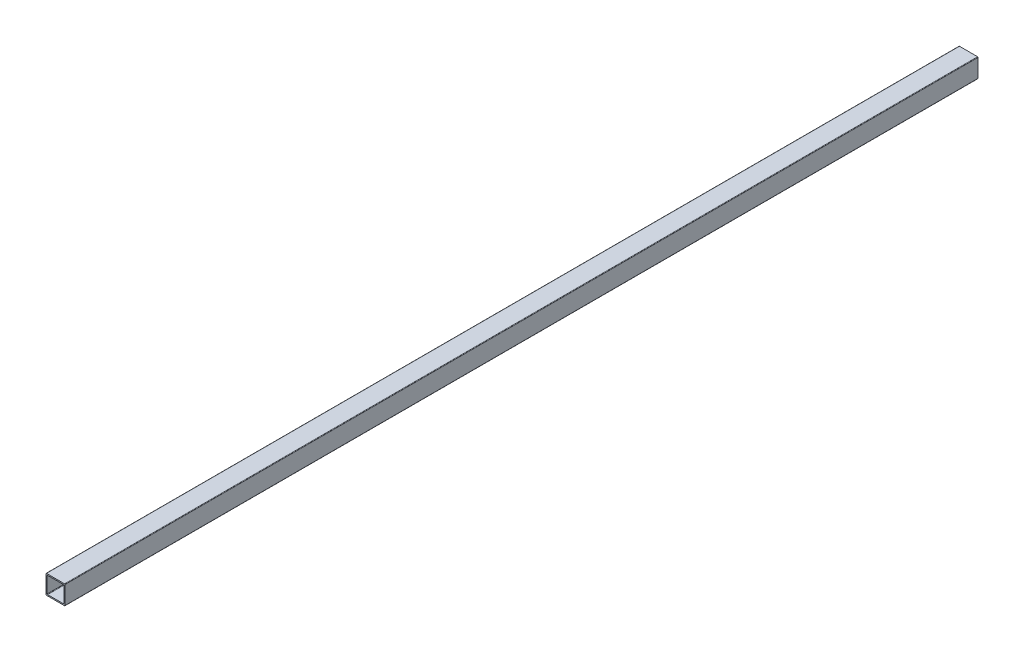
from build123d import *

# Parameters (mm, degrees)
SQUARE_TUBE_1_INCH_SQUARE_0_0625_THICK_1_DEPTH = 1219.2


with BuildPart() as part:
    # Sketch2 → Square tube 1 INCH SQUARE 0.0625 THICK(1) (new body)
    with BuildSketch(Plane.XY):
        with BuildLine():
            Line((12.065, -12.7), (-12.065, -12.7))
            ThreePointArc((-12.065, -12.7), (-12.514012806, -12.514012806), (-12.7, -12.065))
            Line((-12.7, -12.065), (-12.7, 12.065))
            ThreePointArc((-12.7, 12.065), (-12.514012806, 12.514012806), (-12.065, 12.7))
            Line((-12.065, 12.7), (12.065, 12.7))
            ThreePointArc((12.065, 12.7), (12.514012806, 12.514012806), (12.7, 12.065))
            Line((12.7, 12.065), (12.7, -12.065))
            ThreePointArc((12.7, -12.065), (12.514012806, -12.514012806), (12.065, -12.7))
        make_face()
        with BuildLine():
            Line((-11.1125, -10.4775), (-11.1125, 10.4775))
            ThreePointArc((-11.1125, 10.4775), (-10.926512806, 10.926512806), (-10.4775, 11.1125))
            Line((-10.4775, 11.1125), (10.4775, 11.1125))
            ThreePointArc((10.4775, 11.1125), (10.926512806, 10.926512806), (11.1125, 10.4775))
            Line((11.1125, 10.4775), (11.1125, -10.4775))
            ThreePointArc((11.1125, -10.4775), (10.926512806, -10.926512806), (10.4775, -11.1125))
            Line((10.4775, -11.1125), (-10.4775, -11.1125))
            ThreePointArc((-10.4775, -11.1125), (-10.926512806, -10.926512806), (-11.1125, -10.4775))
        make_face(mode=Mode.SUBTRACT)
    extrude(amount=SQUARE_TUBE_1_INCH_SQUARE_0_0625_THICK_1_DEPTH)


solid = part.part
